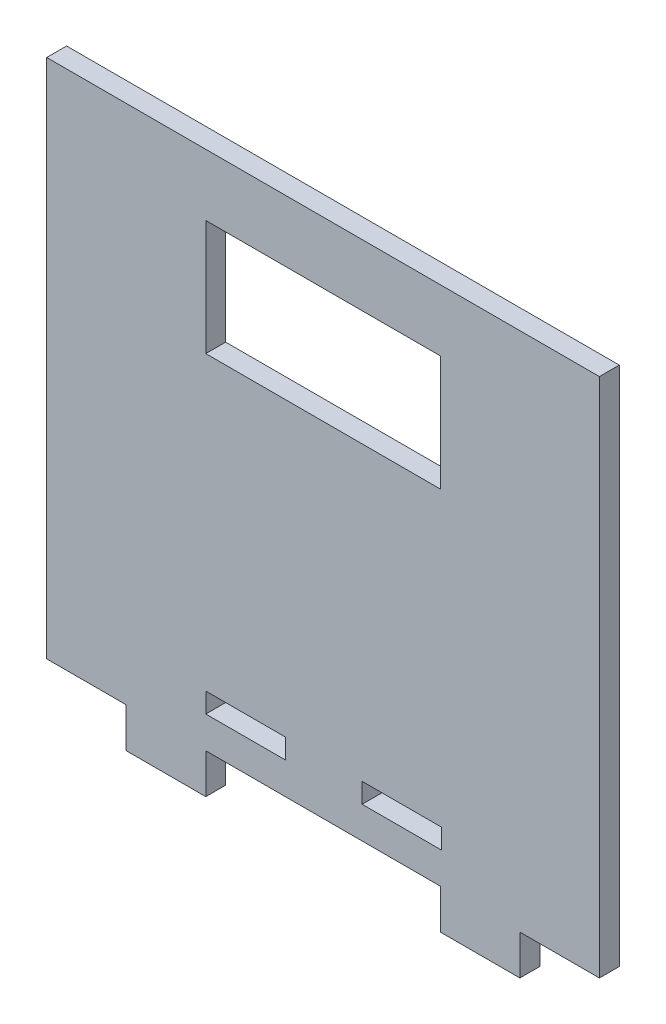
from build123d import *

# Parameters (mm, degrees)
SKETCH1_W           = 139
SKETCH1_H           = 131
SKETCH1_W_2         = 20
SKETCH1_H_2         = 5
SKETCH1_W_3         = 59
SKETCH1_H_3         = 29
SKETCH1_H_4         = 10
BOSS_EXTRUDE2_DEPTH = 5


with BuildPart() as part:
    # Sketch1 → Boss-Extrude2 (new body)
    with BuildSketch(Plane.XY):
        Rectangle(SKETCH1_W, SKETCH1_H)
        with Locations((-19.5, -55)):
            Rectangle(SKETCH1_W_2, SKETCH1_H_2, mode=Mode.SUBTRACT)
        with Locations((19.819504059, -55)):
            Rectangle(SKETCH1_W_2, SKETCH1_H_2, mode=Mode.SUBTRACT)
        with Locations((0, 35.5)):
            Rectangle(SKETCH1_W_3, SKETCH1_H_3, mode=Mode.SUBTRACT)
        with Locations((-39.5, -70.5)):
            Rectangle(SKETCH1_W_2, SKETCH1_H_4)
        with Locations((39.5, -70.5)):
            Rectangle(SKETCH1_W_2, SKETCH1_H_4)
    extrude(amount=BOSS_EXTRUDE2_DEPTH)


solid = part.part
